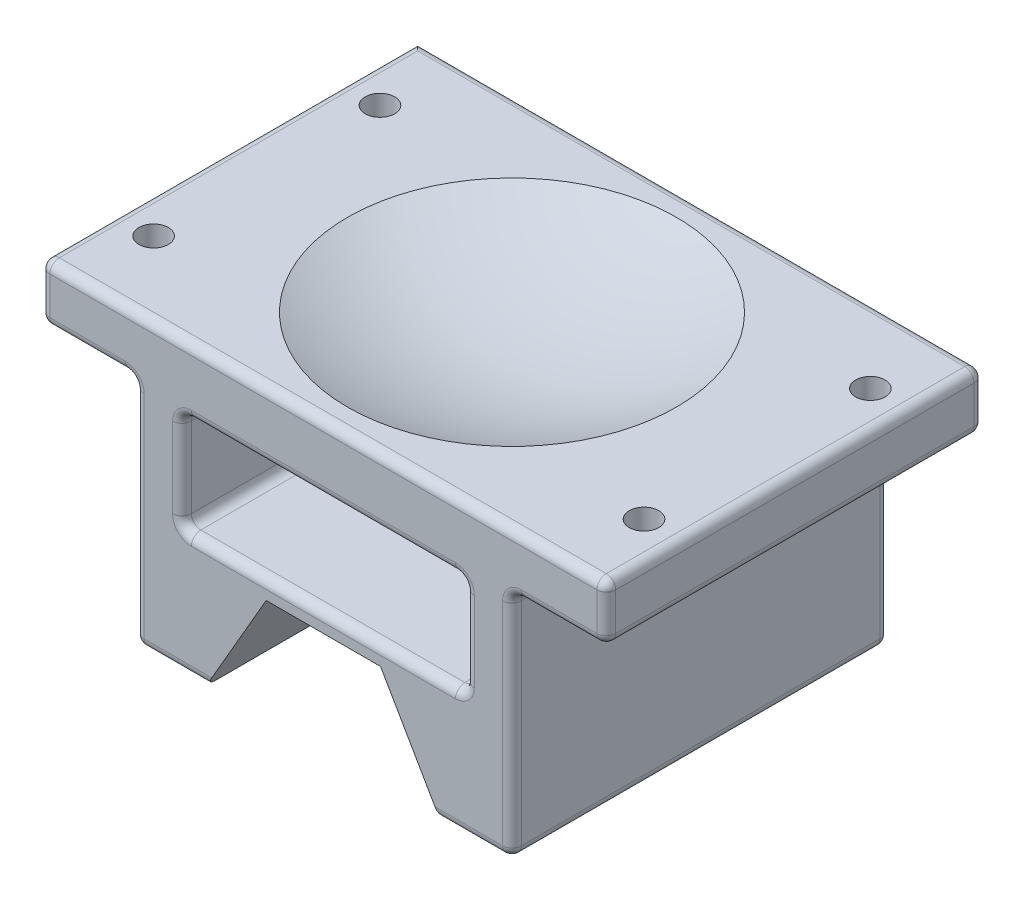
from build123d import *

# Parameters (mm, degrees)
BASE_EXTRUDE_DEPTH                     = 254
SKETCH2_R                              = 9.9187
CUT_EXTRUDE1_DEPTH                     = 194.675
FILLET1_R                              = 6.35
SKETCH6_W                              = 190.5
SKETCH6_H                              = 66.675
CUT_EXTRUDE3_DEPTH                     = 255
FILLET2_R                              = 6.35
TAPPED_HOLE_FOR_3_4_16_HELICOIL1_D     = 19.44624
TAPPED_HOLE_FOR_3_4_16_HELICOIL1_DEPTH = 38.3032
TAPPED_HOLE_FOR_3_4_16_HELICOIL1_TIP   = 5.842239902


with BuildPart() as part:
    # Sketch1 → Base-Extrude (new body)
    with BuildSketch(Plane.XY):
        Polygon((38.494829198, 73.025), (-38.494829198, 73.025), (-78.822745501, 3.175), (-127, 3.175), (-127, 158.75), (-190.5, 158.75), (-190.5, 196.85), (190.5, 196.85), (190.5, 158.75), (127, 158.75), (127, 3.175), (78.822745501, 3.175), align=None)
    extrude(amount=BASE_EXTRUDE_DEPTH)

    # Sketch2 → Cut-Extrude1 (cut, through all)
    with BuildSketch(Plane(origin=(0, 196.85, 0), x_dir=(-1, 0, 0), z_dir=(0, 1, 0))):
        with Locations(Location((-165.1, 50.8, 0), (0, 0, 90))):  # turned: the seam where the file's is
            Circle(SKETCH2_R)
        with Locations(Location((-165.1, 203.2, 0), (0, 0, 90))):  # turned: the seam where the file's is
            Circle(SKETCH2_R)
        with Locations(Location((165.1, 203.2, 0), (0, 0, 90))):  # turned: the seam where the file's is
            Circle(SKETCH2_R)
        with Locations(Location((165.1, 50.8, 0), (0, 0, 90))):  # turned: the seam where the file's is
            Circle(SKETCH2_R)
    extrude(amount=-CUT_EXTRUDE1_DEPTH, mode=Mode.SUBTRACT)

    # Sketch5 → Cut-Revolve1 (revolve, cut)
    with BuildSketch(Plane(origin=(0, 0, 0), x_dir=(0, 0, -1), z_dir=(1, 0, 0)), mode=Mode.PRIVATE) as cut_revolve1_sk:
        with BuildLine():
            Line((-127, 171.45), (-127, 196.85))
            Line((-127, 196.85), (-16.283966834, 196.85))
            ThreePointArc((-16.283966834, 196.85), (-70.203873372, 177.881423642), (-127, 171.45))
        make_face()
    revolve(cut_revolve1_sk.sketch.rotate(Axis((0, 142.323170727, 127), (0, -1, 0)), 180), axis=Axis((0, 142.323170727, 127), (0, -1, 0)), mode=Mode.SUBTRACT)  # turned: the seam where the file's is

    # Fillet1
    fillet1_edges = [part.edges().sort_by_distance(p)[0] for p in [
        (-127, 80.9625, 0),
        (-158.75, 158.75, 0),
        (0, 196.85, 0),
        (190.5, 177.8, 0),
        (158.75, 158.75, 0),
        (127, 80.9625, 0),
        (102.911372751, 3.175, 0),
        (-102.911372751, 3.175, 0),
        (102.911372751, 3.175, 254),
        (127, 80.9625, 254),
        (-127, 3.175, 127),
        (-127, 158.75, 127),
        (-190.5, 158.75, 127),
        (-190.5, 196.85, 127),
        (190.5, 196.85, 127),
        (190.5, 158.75, 127),
        (127, 158.75, 127),
        (127, 3.175, 127),
        (158.75, 158.75, 254),
        (190.5, 177.8, 254),
        (0, 196.85, 254),
        (-190.5, 177.8, 254),
        (-158.75, 158.75, 254),
        (-127, 80.9625, 254),
        (-102.911372751, 3.175, 254),
    ]]
    fillet(fillet1_edges, radius=FILLET1_R)

    # Sketch6 → Cut-Extrude3 (cut, through all)
    with BuildSketch(Plane.XY.offset(254)):
        with Locations((0, 119.0625)):
            Rectangle(SKETCH6_W, SKETCH6_H)
    extrude(amount=-CUT_EXTRUDE3_DEPTH, mode=Mode.SUBTRACT)

    # Fillet2
    fillet2_edges = [part.edges().sort_by_distance(p)[0] for p in [
        (-95.25, 119.0625, 0),
        (-95.25, 85.725, 127),
        (0, 152.4, 254),
        (-95.25, 152.4, 127),
        (95.25, 119.0625, 0),
        (95.25, 152.4, 127),
        (0, 85.725, 254),
        (95.25, 85.725, 127),
        (0, 152.4, 0),
        (0, 85.725, 0),
        (-95.25, 119.0625, 254),
        (95.25, 119.0625, 254),
    ]]
    fillet(fillet2_edges, radius=FILLET2_R)

    # Tapped Hole for 3_4-16 Helicoil1
    with Locations(Plane.XZ.offset(-3.175)):
        with Locations((-103.124, 203.2), (-103.124, 50.8), (103.124, 203.2), (103.124, 50.8)):
            Hole(TAPPED_HOLE_FOR_3_4_16_HELICOIL1_D / 2, depth=TAPPED_HOLE_FOR_3_4_16_HELICOIL1_DEPTH)
            with Locations((0, 0, -(TAPPED_HOLE_FOR_3_4_16_HELICOIL1_DEPTH + TAPPED_HOLE_FOR_3_4_16_HELICOIL1_TIP / 2))):  # 118° drill point
                Cone(0, TAPPED_HOLE_FOR_3_4_16_HELICOIL1_D / 2, TAPPED_HOLE_FOR_3_4_16_HELICOIL1_TIP, mode=Mode.SUBTRACT)


solid = part.part
